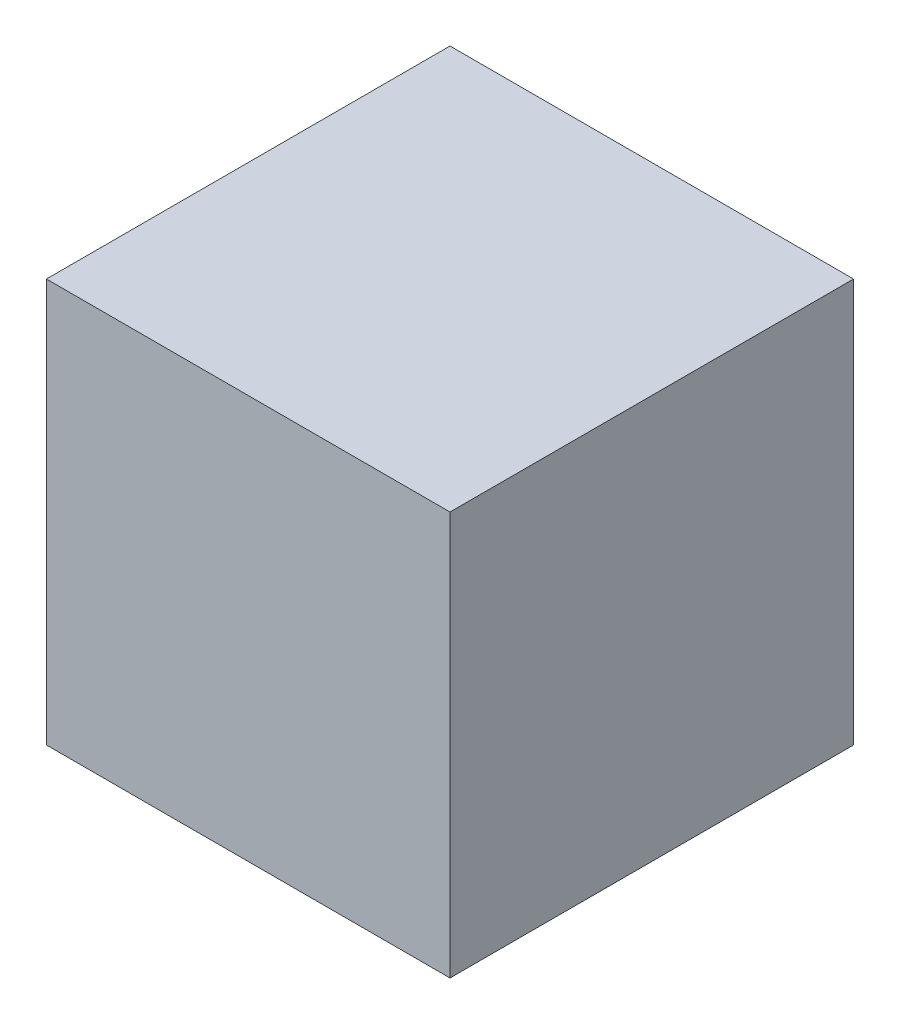
from build123d import *

# Parameters (mm, degrees)
ESBO_O1_W                = 10
ESBO_O1_H                = 10
RESSALTO_EXTRUS_O1_DEPTH = 5


with BuildPart() as part:
    # Esboço1 → Ressalto-extrusão1 (new body, symmetric)
    with BuildSketch(Plane(origin=(0, 0, 0), x_dir=(1, 0, 0), z_dir=(0, 1, 0))):
        Rectangle(ESBO_O1_W, ESBO_O1_H)
    extrude(amount=RESSALTO_EXTRUS_O1_DEPTH, both=True)


solid = part.part
